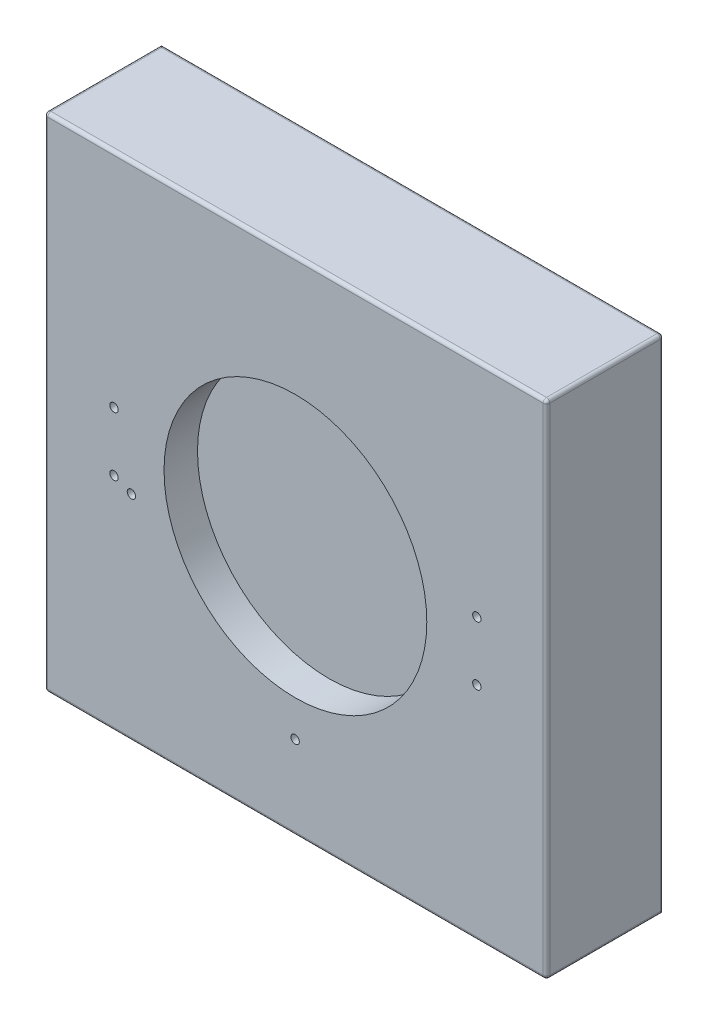
from build123d import *

# Parameters (mm, degrees)
SKETCH1_W                   = 150
SKETCH1_H                   = 150
BOSS_EXTRUDE1_DEPTH         = 35
FILLET1_R                   = 1
SKETCH2_R                   = 39.25
CUT_EXTRUDE4_DEPTH          = 10
TAP_DRILL_FOR_M3X0_5_TAP2_D = 2.5
TAP_DRILL_FOR_M3X0_5_TAP3_D = 2.5
TAP_DRILL_FOR_M3X0_5_TAP5_D = 2.5
SKETCH31_W                  = 40.1
SKETCH31_H                  = 50
CUT_EXTRUDE5_DEPTH          = 20.3


with BuildPart() as part:
    # Sketch1 → Boss-Extrude1 (new body)
    with BuildSketch(Plane.XY):
        Rectangle(SKETCH1_W, SKETCH1_H)
    extrude(amount=-BOSS_EXTRUDE1_DEPTH)

    # Fillet1
    fillet1_edges = [part.edges().sort_by_distance(p)[0] for p in [
        (75, -75, -17.5),
        (-75, -75, -17.5),
        (-75, 75, -17.5),
        (75, 0, -35),
        (0, 75, -35),
        (75, 75, -17.5),
        (0, -75, 0),
        (-75, 0, 0),
        (75, 0, 0),
        (0, 75, 0),
    ]]
    fillet(fillet1_edges, radius=FILLET1_R)

    # Sketch2 → Cut-Extrude4 (cut)
    with BuildSketch(Plane.XY):
        Circle(SKETCH2_R)
    extrude(amount=-CUT_EXTRUDE4_DEPTH, mode=Mode.SUBTRACT)

    # Tap Drill for M3x0.5 Tap2 (through all)
    with Locations(Plane.XY):
        with Locations((-54.190883488, -8.8), (-54.190883488, 8.8), (54.190883488, -8.8), (54.190883488, 8.8)):
            Hole(TAP_DRILL_FOR_M3X0_5_TAP2_D / 2)

    # Tap Drill for M3x0.5 Tap3 (through all)
    with Locations(Plane.XY):
        with Locations((-49, -11)):
            Hole(TAP_DRILL_FOR_M3X0_5_TAP3_D / 2)

    # Tap Drill for M3x0.5 Tap5 (through all)
    with Locations(Plane.XY):
        with Locations((-0.083892693, -49.999977478)):
            Hole(TAP_DRILL_FOR_M3X0_5_TAP5_D / 2)

    # Sketch31 → Cut-Extrude5 (cut)
    with BuildSketch(Plane(origin=(0, 0, -35), x_dir=(-1, 0, 0), z_dir=(0, 0, -1))):
        Rectangle(SKETCH31_W, SKETCH31_H)
    extrude(amount=-CUT_EXTRUDE5_DEPTH, mode=Mode.SUBTRACT)


solid = part.part
